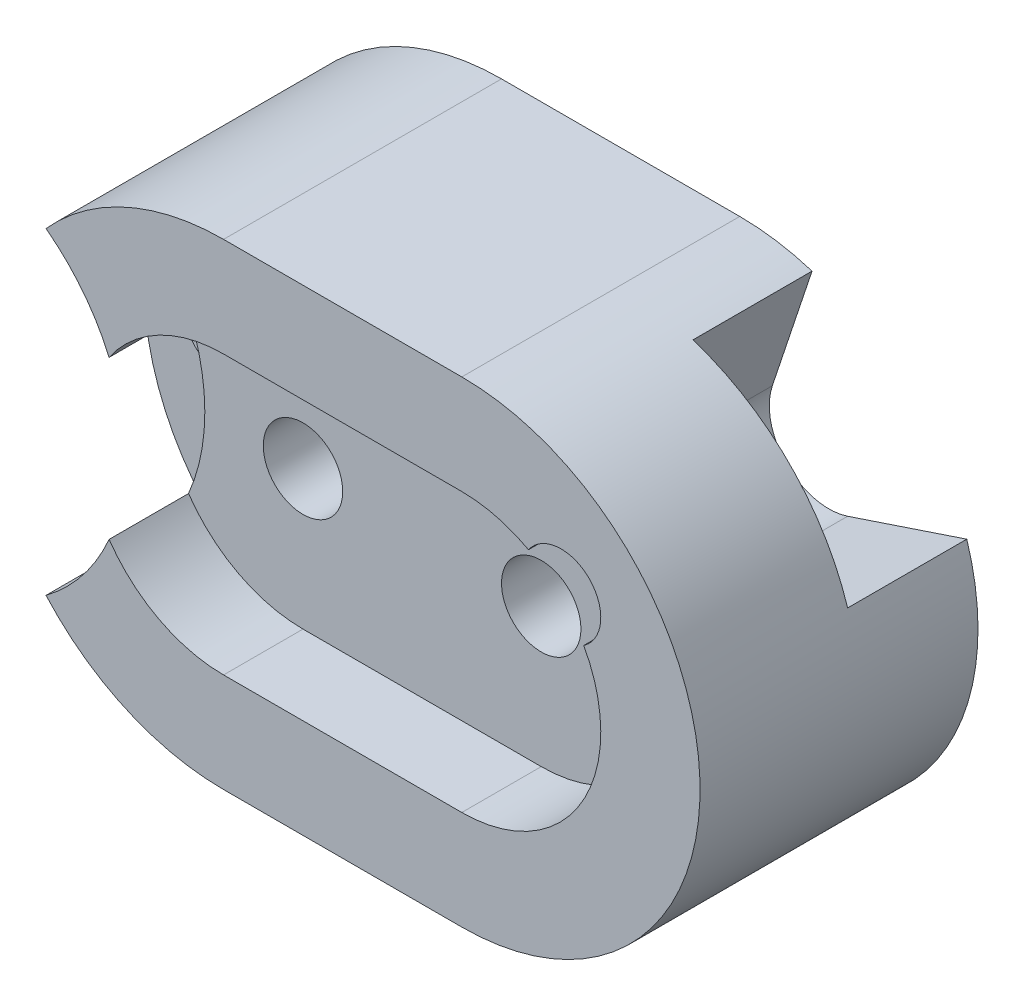
from build123d import *

# Parameters (mm, degrees)
BOSS_EXTRUDE1_DEPTH = 35
CUT_EXTRUDE1_DEPTH  = 10
SKETCH4_R           = 5
CUT_EXTRUDE2_DEPTH  = 113
SKETCH5_R           = 5
CUT_EXTRUDE3_DEPTH  = 20
CUT_EXTRUDE4_DEPTH  = 20
SKETCH7_R           = 5
CUT_EXTRUDE5_DEPTH  = 48
CUT_EXTRUDE7_DEPTH  = 15


with BuildPart() as part:
    # Sketch1 → Boss-Extrude1 (new body)
    with BuildSketch(Plane.XY):
        with BuildLine():
            Line((-30, 60), (0, 60))
            ThreePointArc((0, 60), (30, 30), (0, 0))
            Line((0, 0), (-30, 0))
            ThreePointArc((-30, 0), (-60, 30), (-30, 60))
        make_face()
    extrude(amount=BOSS_EXTRUDE1_DEPTH)

    # Sketch2 → Cut-Extrude1 (cut)
    with BuildSketch(Plane.XY.offset(35)):
        with BuildLine():
            Line((-30, 47.5), (0, 47.5))
            ThreePointArc((0, 47.5), (17.5, 30), (0, 12.5))
            Line((0, 12.5), (-30, 12.5))
            ThreePointArc((-30, 12.5), (-47.5, 30), (-30, 47.5))
        make_face()
    extrude(amount=-CUT_EXTRUDE1_DEPTH, mode=Mode.SUBTRACT)

    # Sketch4 → Cut-Extrude2 (cut)
    with BuildSketch(Plane.XY.offset(25)):
        with Locations((-30, 30)):
            Circle(SKETCH4_R)
        with Locations((0, 30)):
            Circle(SKETCH4_R)
    extrude(amount=-CUT_EXTRUDE2_DEPTH, mode=Mode.SUBTRACT)

    # Sketch5 → Cut-Extrude3 (cut)
    with BuildSketch(Plane.XY.offset(35)):
        with Locations((12.5, 42.5)):
            Circle(SKETCH5_R)
    extrude(amount=-CUT_EXTRUDE3_DEPTH, mode=Mode.SUBTRACT)

    # Sketch6 → Cut-Extrude4 (cut)
    with BuildSketch(Plane.XY.offset(35)):
        with BuildLine():
            ThreePointArc((-52.360679775, 50), (-42.360679775, 30), (-52.360679775, 10))
            ThreePointArc((-52.360679775, 10), (-60, 30), (-52.360679775, 50))
        make_face()
    extrude(amount=-CUT_EXTRUDE4_DEPTH, mode=Mode.SUBTRACT)

    # Sketch7 → Cut-Extrude5 (cut)
    with BuildSketch(Plane.XY.offset(15)):
        with Locations((-50, 30)):
            Circle(SKETCH7_R)
    extrude(amount=-CUT_EXTRUDE5_DEPTH, mode=Mode.SUBTRACT)

    # Sketch8 → Cut-Extrude7 (cut)
    with BuildSketch(Plane(origin=(0, 0, 0), x_dir=(-1, 0, 0), z_dir=(0, 0, -1))):
        with BuildLine():
            Line((-4.099774192, 43.586607173), (-9.099774192, 58.586607173))
            ThreePointArc((-9.099774192, 58.586607173), (-21.213203436, 51.213203436), (-28.586607173, 39.099774192))
            Line((-28.586607173, 39.099774192), (-13.586607173, 34.099774192))
            ThreePointArc((-13.586607173, 34.099774192), (-5.911598069, 35.911598069), (-4.099774192, 43.586607173))
        make_face()
    extrude(amount=-CUT_EXTRUDE7_DEPTH, mode=Mode.SUBTRACT)


solid = part.part
